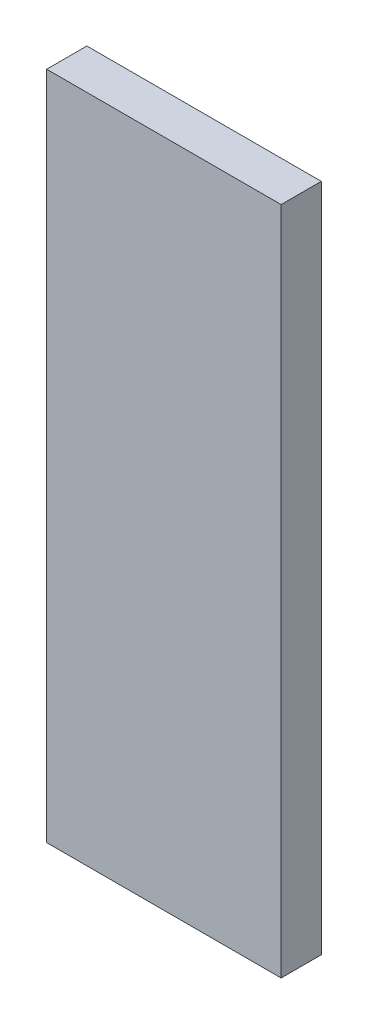
from build123d import *

# Parameters (mm, degrees)
SKETCH1_W           = 17.5
SKETCH1_H           = 50
BOSS_EXTRUDE1_DEPTH = 3


with BuildPart() as part:
    # Sketch1 → Boss-Extrude1 (new body)
    with BuildSketch(Plane.XY):
        Rectangle(SKETCH1_W, SKETCH1_H)
    extrude(amount=BOSS_EXTRUDE1_DEPTH)


solid = part.part
